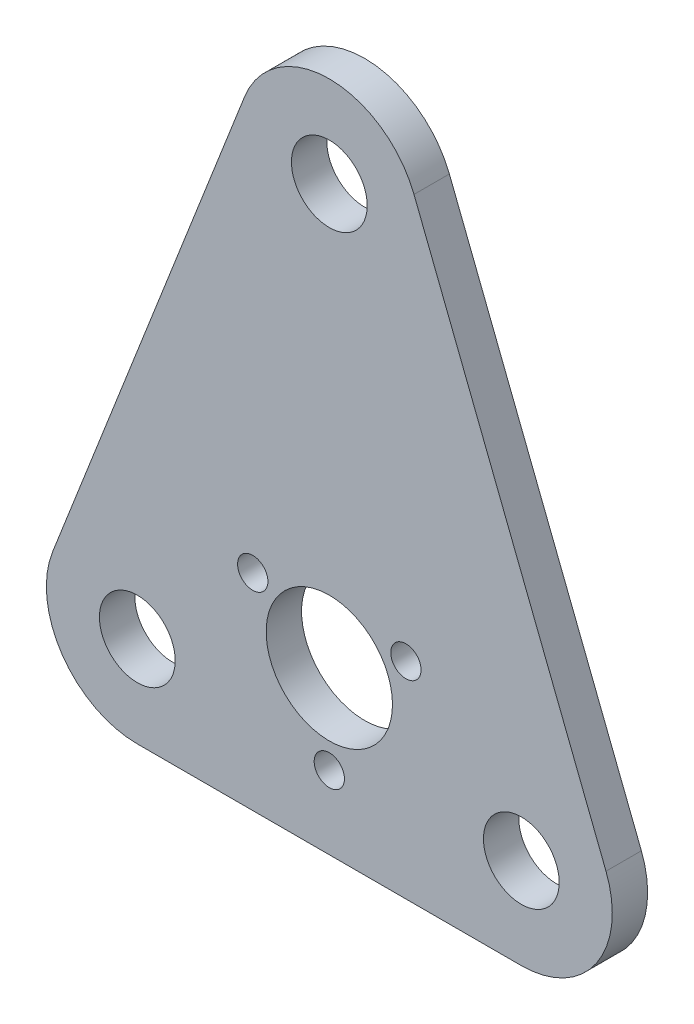
from build123d import *

# Parameters (mm, degrees)
SKETCH1_R           = 7.5
SKETCH1_R_2         = 12.5
SKETCH1_R_3         = 3
BOSS_EXTRUDE1_DEPTH = 7


with BuildPart() as part:
    # Sketch1 → Boss-Extrude1 (new body)
    with BuildSketch(Plane.XY):
        with BuildLine():
            Line((-54.759819531, 6.565702497), (-16.759819531, 103.565702497))
            ThreePointArc((-16.759819531, 103.565702497), (0, 115), (16.759819531, 103.565702497))
            Line((16.759819531, 103.565702497), (54.759819531, 6.565702497))
            ThreePointArc((54.759819531, 6.565702497), (52.869139937, -10.144391432), (38, -18))
            Line((38, -18), (-38, -18))
            ThreePointArc((-38, -18), (-52.869139937, -10.144391432), (-54.759819531, 6.565702497))
        make_face()
        with Locations((0, 97)):
            Circle(SKETCH1_R, mode=Mode.SUBTRACT)
        with Locations((-38, 0)):
            Circle(SKETCH1_R, mode=Mode.SUBTRACT)
        with Locations((38, 0)):
            Circle(SKETCH1_R, mode=Mode.SUBTRACT)
        with Locations((0, 14)):
            Circle(SKETCH1_R_2, mode=Mode.SUBTRACT)
        with Locations((0, -3.5)):
            Circle(SKETCH1_R_3, mode=Mode.SUBTRACT)
        with Locations((-15.155444566, 22.75)):
            Circle(SKETCH1_R_3, mode=Mode.SUBTRACT)
        with Locations((15.155444566, 22.75)):
            Circle(SKETCH1_R_3, mode=Mode.SUBTRACT)
    extrude(amount=BOSS_EXTRUDE1_DEPTH)


solid = part.part
